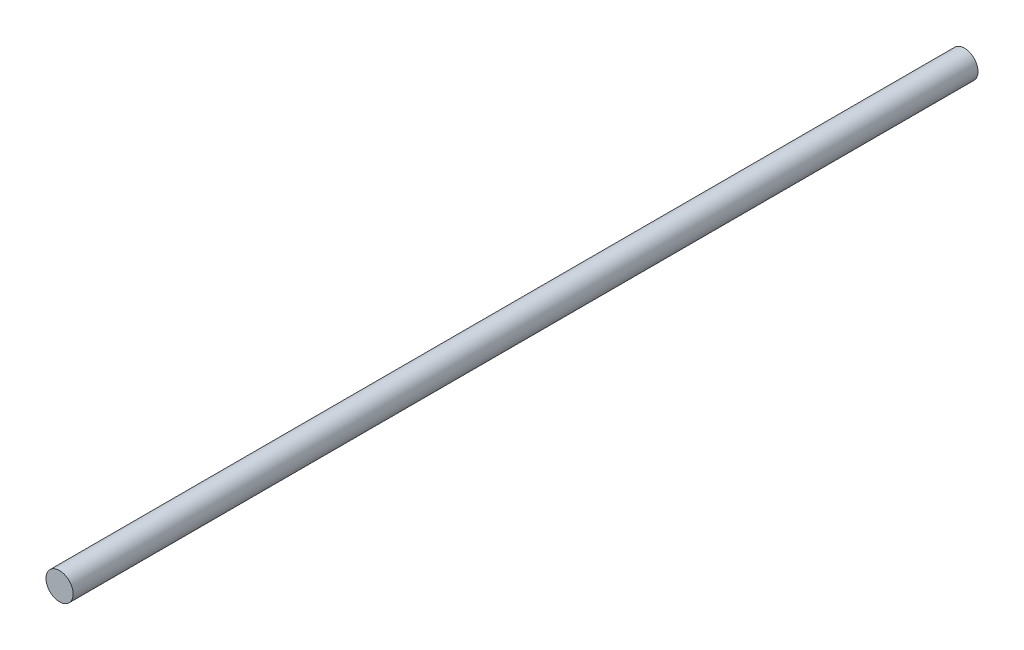
from build123d import *

# Parameters (mm, degrees)
SKETCH1_R           = 1.5
BOSS_EXTRUDE1_DEPTH = 100


with BuildPart() as part:
    # Sketch1 → Boss-Extrude1 (new body)
    with BuildSketch(Plane.XY):
        Circle(SKETCH1_R)
    extrude(amount=BOSS_EXTRUDE1_DEPTH)


solid = part.part
